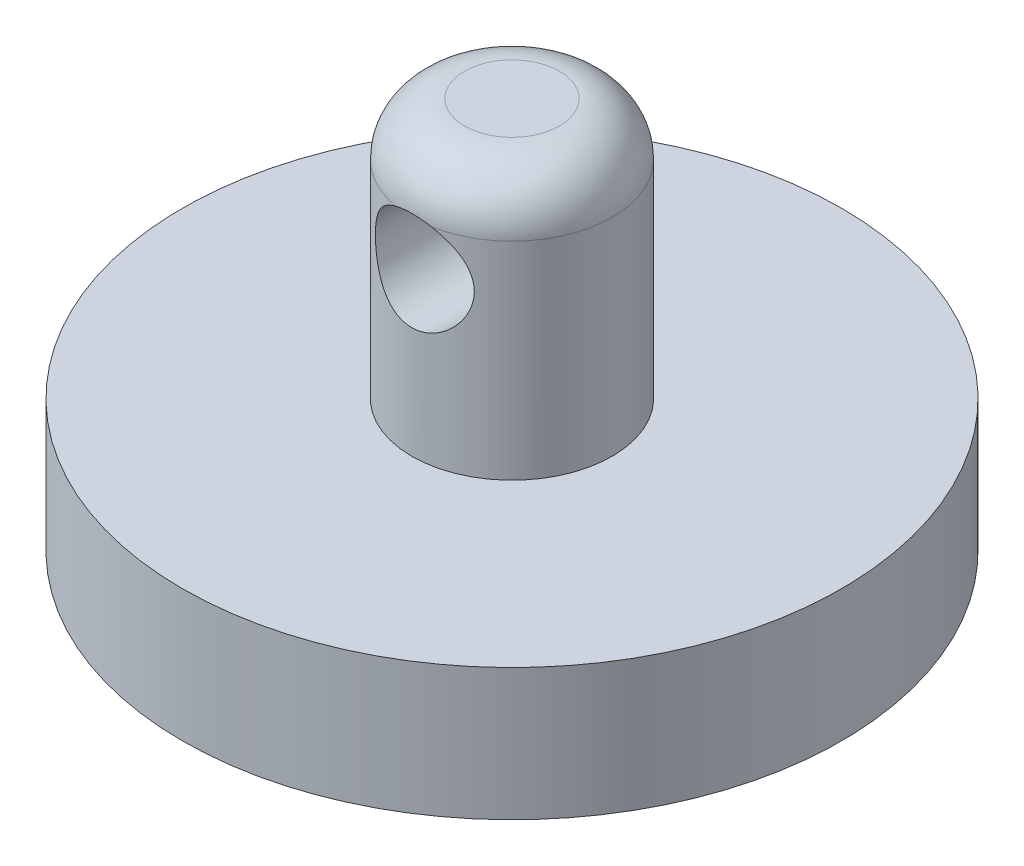
from build123d import *

# Parameters (mm, degrees)
SKETCH3_R          = 2.38125
CUT_EXTRUDE1_DEPTH = 19.045054718


with BuildPart() as part:
    # Sketch1 → Revolve1 (revolve)
    with BuildSketch(Plane.XY):
        with BuildLine():
            Line((0, 0), (2.286, 0))
            ThreePointArc((2.286, 0), (4.082051224, -0.743948776), (4.826, -2.54))
            Line((4.826, -2.54), (4.826, -12.5095))
            Line((4.826, -12.5095), (15.875, -12.5095))
            Line((15.875, -12.5095), (15.875, -18.8595))
            Line((15.875, -18.8595), (12.7, -18.8595))
            Line((12.7, -18.8595), (12.7, -15.6845))
            Line((12.7, -15.6845), (0, -15.6845))
            Line((0, -15.6845), (0, 0))
        make_face()
    revolve(axis=Axis((0, 0, 0), (0, -1, 0)))

    # Sketch3 → Cut-Extrude1 (cut)
    with BuildSketch(Plane.XY.offset(4.826)):
        with Locations((0, -4.7625)):
            Circle(SKETCH3_R)
    extrude(amount=-CUT_EXTRUDE1_DEPTH, mode=Mode.SUBTRACT)


solid = part.part
